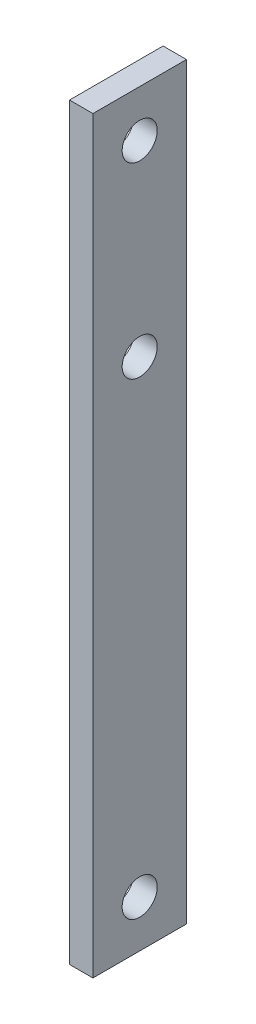
from build123d import *

# Parameters (mm, degrees)
SKETCH1_W           = 50.8
SKETCH1_H           = 406.4
BOSS_EXTRUDE1_DEPTH = 6.35
CUT_EXTRUDE1_REACH  = 14.7
SKETCH2_R           = 9.525


with BuildPart() as part:
    # Sketch1 → Boss-Extrude1 (new body, symmetric)
    with BuildSketch(Plane(origin=(0, 0, 0), x_dir=(0, 0, -1), z_dir=(1, 0, 0))):
        Rectangle(SKETCH1_W, SKETCH1_H)
    extrude(amount=BOSS_EXTRUDE1_DEPTH, both=True)

    # Sketch2 → Cut-Extrude1 (cut, up to next)
    with BuildSketch(Plane(origin=(6.35, 0, 0), x_dir=(0, 0, -1), z_dir=(1, 0, 0)), mode=Mode.PRIVATE) as cut_extrude1_sk1:
        with Locations((0, 177.8)):
            Circle(SKETCH2_R)
    cut_extrude1_tool1 = extrude(cut_extrude1_sk1.sketch, amount=-CUT_EXTRUDE1_REACH, mode=Mode.PRIVATE) & part.part
    add(cut_extrude1_tool1.solids().sort_by_distance((6.35, 177.8, 0))[0], mode=Mode.SUBTRACT)
    # Sketch2 → Cut-Extrude1 (cut, up to next)
    with BuildSketch(Plane(origin=(6.35, 0, 0), x_dir=(0, 0, -1), z_dir=(1, 0, 0)), mode=Mode.PRIVATE) as cut_extrude1_sk2:
        with Locations((0, -177.8)):
            Circle(SKETCH2_R)
    cut_extrude1_tool2 = extrude(cut_extrude1_sk2.sketch, amount=-CUT_EXTRUDE1_REACH, mode=Mode.PRIVATE) & part.part
    add(cut_extrude1_tool2.solids().sort_by_distance((6.35, -177.8, 0))[0], mode=Mode.SUBTRACT)
    # Sketch2 → Cut-Extrude1 (cut, up to next)
    with BuildSketch(Plane(origin=(6.35, 0, 0), x_dir=(0, 0, -1), z_dir=(1, 0, 0)), mode=Mode.PRIVATE) as cut_extrude1_sk3:
        with Locations((0, 76.2)):
            Circle(SKETCH2_R)
    cut_extrude1_tool3 = extrude(cut_extrude1_sk3.sketch, amount=-CUT_EXTRUDE1_REACH, mode=Mode.PRIVATE) & part.part
    add(cut_extrude1_tool3.solids().sort_by_distance((6.35, 76.2, 0))[0], mode=Mode.SUBTRACT)


solid = part.part
